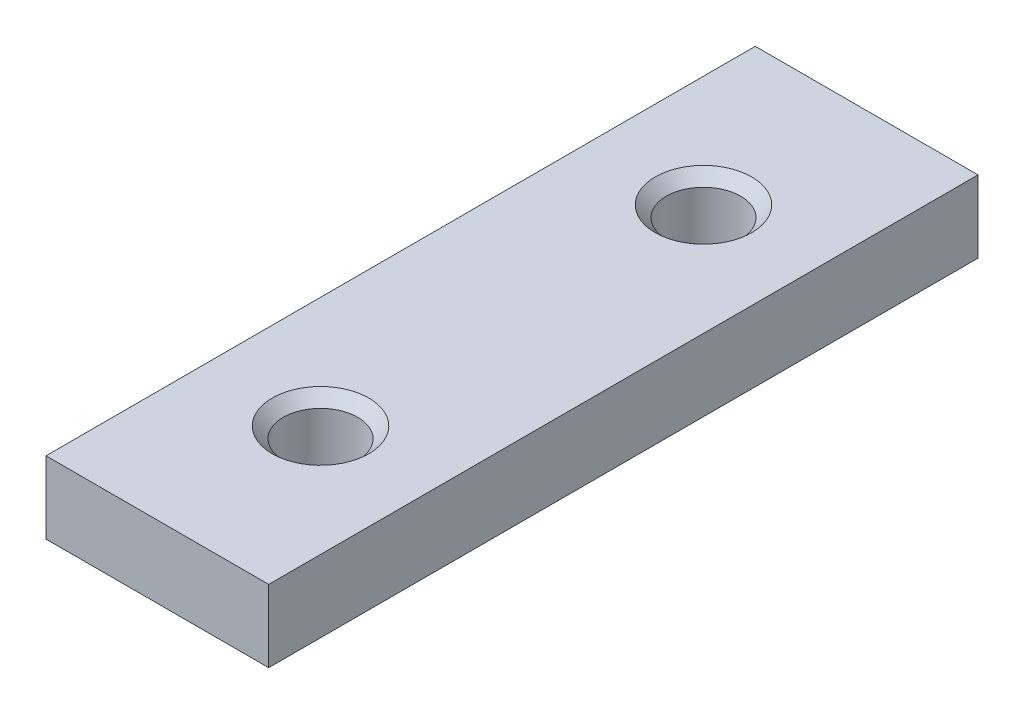
from build123d import *

# Parameters (mm, degrees)
SKETCH1_W           = 20.06486665
SKETCH1_H           = 63.9
SKETCH1_R           = 3.35
BOSS_EXTRUDE1_DEPTH = 6.5
CHAMFER1_SIZE       = 1


with BuildPart() as part:
    # Sketch1 → Boss-Extrude1 (new body)
    with BuildSketch(Plane(origin=(0, 0, 0), x_dir=(1, 0, 0), z_dir=(0, 1, 0))):
        with Locations((-10.582433325, -32.5)):
            Rectangle(SKETCH1_W, SKETCH1_H)
        with Locations((-10.582433325, -15.25)):
            Circle(SKETCH1_R, mode=Mode.SUBTRACT)
        with Locations((-10.582433325, -49.75)):
            Circle(SKETCH1_R, mode=Mode.SUBTRACT)
    extrude(amount=BOSS_EXTRUDE1_DEPTH)

    # Chamfer1
    chamfer1_edges = [part.edges().sort_by_distance(p)[0] for p in [
        (-13.932433325, 6.5, 15.25),
        (-13.932433325, 6.5, 49.75),
    ]]
    chamfer(chamfer1_edges, length=CHAMFER1_SIZE)


solid = part.part
